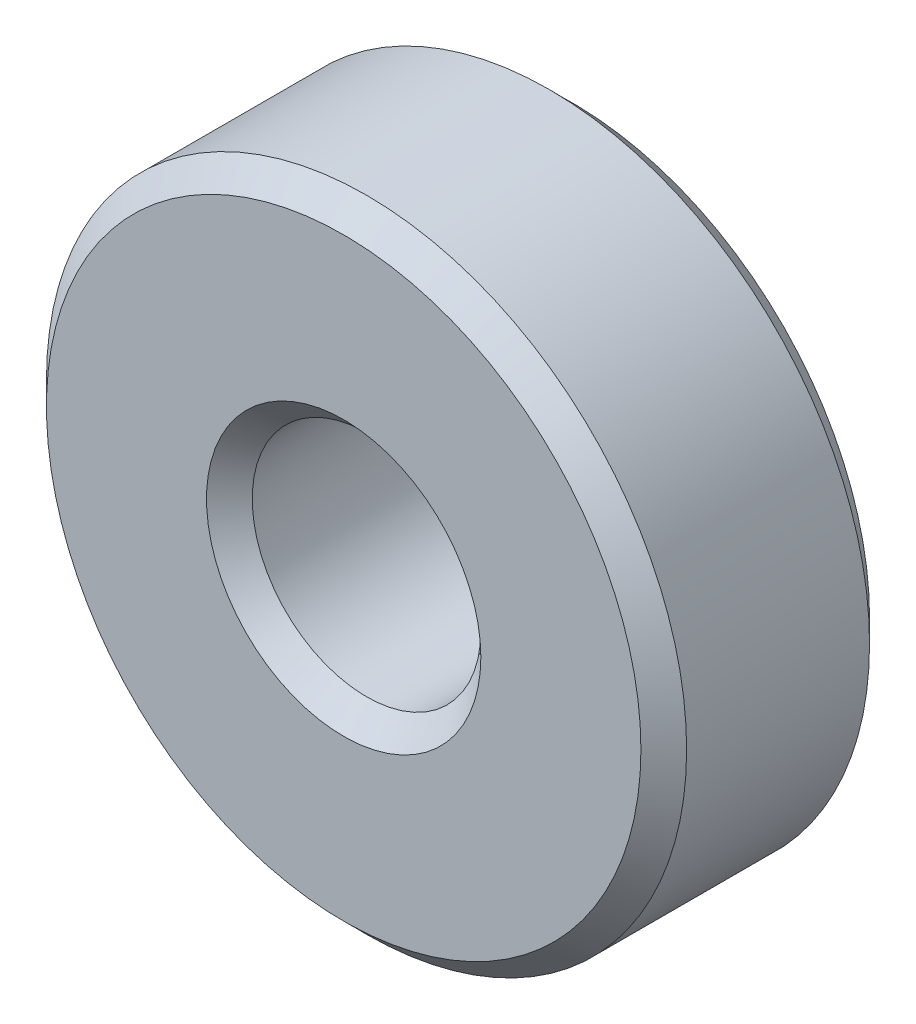
from build123d import *

# Parameters (mm, degrees)
SKETCH1_R           = 7
SKETCH1_R_2         = 2.5
BOSS_EXTRUDE1_DEPTH = 5
CHAMFER1_SIZE       = 0.5


with BuildPart() as part:
    # Sketch1 → Boss-Extrude1 (new body)
    with BuildSketch(Plane.XY):
        Circle(SKETCH1_R)
        Circle(SKETCH1_R_2, mode=Mode.SUBTRACT)
    extrude(amount=BOSS_EXTRUDE1_DEPTH)

    # Chamfer1
    chamfer1_edges = [part.edges().sort_by_distance(p)[0] for p in [
        (-7, 0, 0),
        (-7, 0, 5),
        (-2.5, 0, 0),
        (-2.5, 0, 5),
    ]]
    chamfer(chamfer1_edges, length=CHAMFER1_SIZE)


solid = part.part
